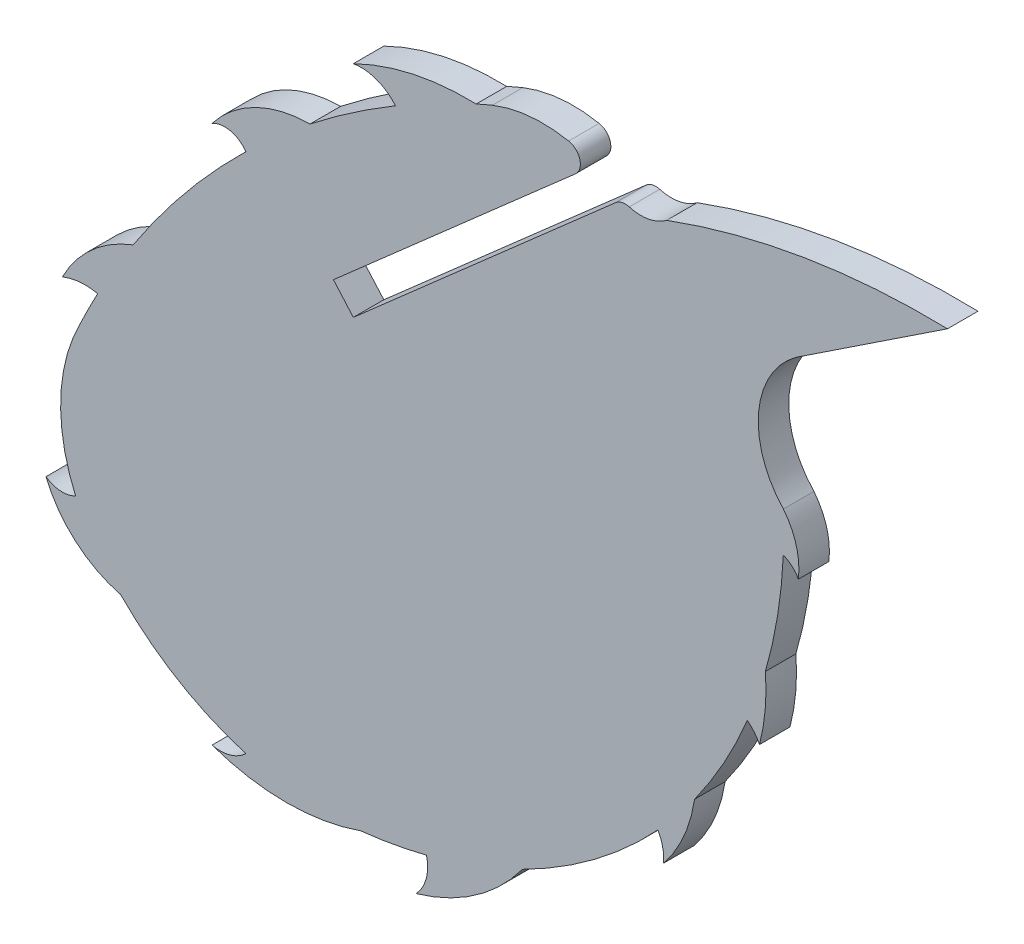
from build123d import *

# Parameters (mm, degrees)
BOSS_EXTRUDE1_DEPTH = 1.524


with BuildPart() as part:
    # Sketch1 → Boss-Extrude1 (new body)
    with BuildSketch(Plane.XY):
        with BuildLine():
            Line((7.568674397, 15.582558464), (-5.536256919, 4.066414385))
            Line((-5.536256919, 4.066414385), (-6.530313076, 5.198282058))
            Line((-6.530313076, 5.198282058), (5.556223507, 15.819133016))
            ThreePointArc((5.556223507, 15.819133016), (5.777089873, 16.550462951), (5.218621489, 17.071748372))
            ThreePointArc((5.218621489, 17.071748372), (3.288269389, 17.169456569), (1.409525645, 16.715443282))
            ThreePointArc((1.409525645, 16.715443282), (1.003306116, 16.541109193), (0.599038273, 16.362295908))
            ThreePointArc((0.599038273, 16.362295908), (-2.550127925, 16.078915888), (-5.536256919, 15.03940369))
            ThreePointArc((-5.536256919, 15.03940369), (-4.380758941, 14.936898454), (-3.431369122, 14.270308722))
            ThreePointArc((-3.431369122, 14.270308722), (-5.61253751, 12.87862193), (-7.699155785, 11.348814153))
            ThreePointArc((-7.699155785, 11.348814153), (-10.424357394, 10.705874365), (-12.591632165, 8.933019197))
            ThreePointArc((-12.591632165, 8.933019197), (-11.673431217, 9.06564735), (-10.902633402, 8.549358731))
            ThreePointArc((-10.902633402, 8.549358731), (-13.90878858, 5.282464583), (-16.534336918, 1.702511755))
            ThreePointArc((-16.534336918, 1.702511755), (-18.59519403, 0.456840392), (-20.068993111, -1.447561206))
            ThreePointArc((-20.068993111, -1.447561206), (-19.197525413, -1.237616175), (-18.302618639, -1.289333967))
            ThreePointArc((-18.302618639, -1.289333967), (-18.746738742, -2.146015126), (-19.170061319, -3.013161751))
            ThreePointArc((-19.170061319, -3.013161751), (-20.151793191, -6.776607347), (-19.40772228, -10.594156129))
            ThreePointArc((-19.40772228, -10.594156129), (-20.160576804, -10.75613538), (-20.886030658, -10.497786933))
            ThreePointArc((-20.886030658, -10.497786933), (-19.40772228, -12.558219915), (-17.161873617, -13.735905577))
            ThreePointArc((-17.161873617, -13.735905577), (-14.272607306, -16.011724419), (-10.902633402, -17.484981731))
            ThreePointArc((-10.902633402, -17.484981731), (-11.686238888, -17.939086495), (-12.591632165, -17.961707434))
            ThreePointArc((-12.591632165, -17.961707434), (-8.881936241, -18.592642939), (-5.172240316, -17.961707434))
            ThreePointArc((-5.172240316, -17.961707434), (-3.516074533, -17.724342682), (-1.880821012, -17.370544649))
            ThreePointArc((-1.880821012, -17.370544649), (-1.897285647, -18.401111131), (-2.412003394, -19.294085934))
            ThreePointArc((-2.412003394, -19.294085934), (0.557596733, -17.882208081), (2.910422529, -15.585224243))
            ThreePointArc((2.910422529, -15.585224243), (6.522466187, -13.346484728), (9.675834999, -10.497786933))
            ThreePointArc((9.675834999, -10.497786933), (9.916567514, -11.124520652), (9.960567596, -11.794454448))
            ThreePointArc((9.960567596, -11.794454448), (10.971969999, -10.129349123), (11.507200123, -8.256106139))
            ThreePointArc((11.507200123, -8.256106139), (12.962197209, -5.968399457), (14.145957127, -3.529274442))
            ThreePointArc((14.145957127, -3.529274442), (14.491523151, -3.864332581), (14.749497984, -4.270693035))
            ThreePointArc((14.749497984, -4.270693035), (15.035659281, -2.627123404), (15.04635356, -0.958862317))
            ThreePointArc((15.04635356, -0.958862317), (15.654704723, 1.754409987), (15.940567857, 4.520313094))
            ThreePointArc((15.940567857, 4.520313094), (16.377113792, 4.256299615), (16.690299619, 3.853571284))
            ThreePointArc((16.690299619, 3.853571284), (16.588539506, 5.261834916), (15.944497262, 6.518326526))
            ThreePointArc((15.944497262, 6.518326526), (14.706822394, 10.090010141), (16.56074466, 13.384207335))
            Line((16.56074466, 13.384207335), (24.140280678, 18.409177712))
            ThreePointArc((24.140280678, 18.409177712), (17.01748918, 17.916684767), (10.115138619, 16.090687846))
            ThreePointArc((10.115138619, 16.090687846), (9.22182641, 15.690950119), (8.244138062, 15.734795847))
            ThreePointArc((8.244138062, 15.734795847), (7.886999128, 15.744784733), (7.568674397, 15.582558464))
        make_face()
    extrude(amount=BOSS_EXTRUDE1_DEPTH)


solid = part.part
